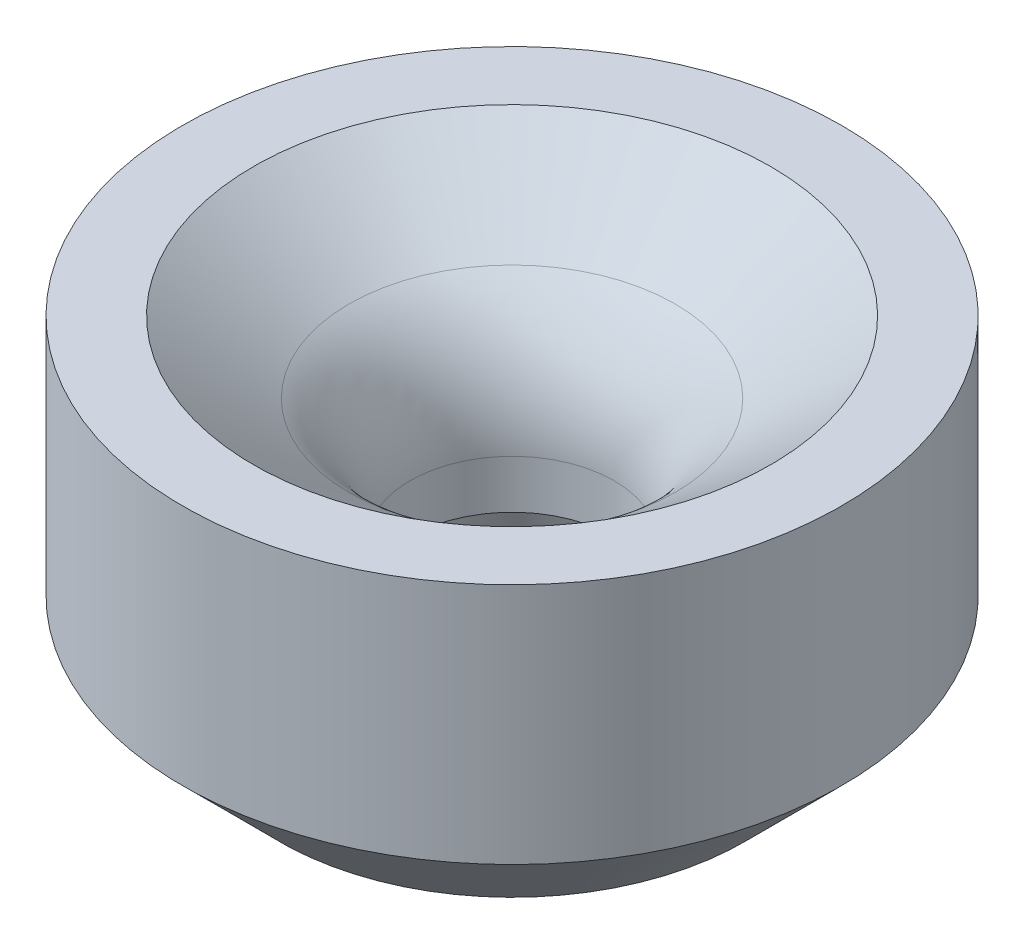
from build123d import *


with BuildPart() as part:
    # Sketch1 → Revolve1 (revolve)
    with BuildSketch(Plane.XY):
        with BuildLine():
            Line((-16.933310091, 12.7), (-10.68830568, 8.01622926))
            ThreePointArc((-10.68830568, 8.01622926), (-7.738067215, 4.481206386), (-6.6802, 0))
            Line((-6.6802, 0), (-6.6802, -3.175))
            Line((-6.6802, -3.175), (-8.621589827, -9.525))
            Line((-8.621589827, -9.525), (-15.24, -9.525))
            Line((-15.24, -9.525), (-21.59, -3.175))
            Line((-21.59, -3.175), (-21.59, 12.7))
            Line((-21.59, 12.7), (-16.933310091, 12.7))
        make_face()
    revolve(axis=Axis((0, 0, 0), (0, 1, 0)))


solid = part.part
